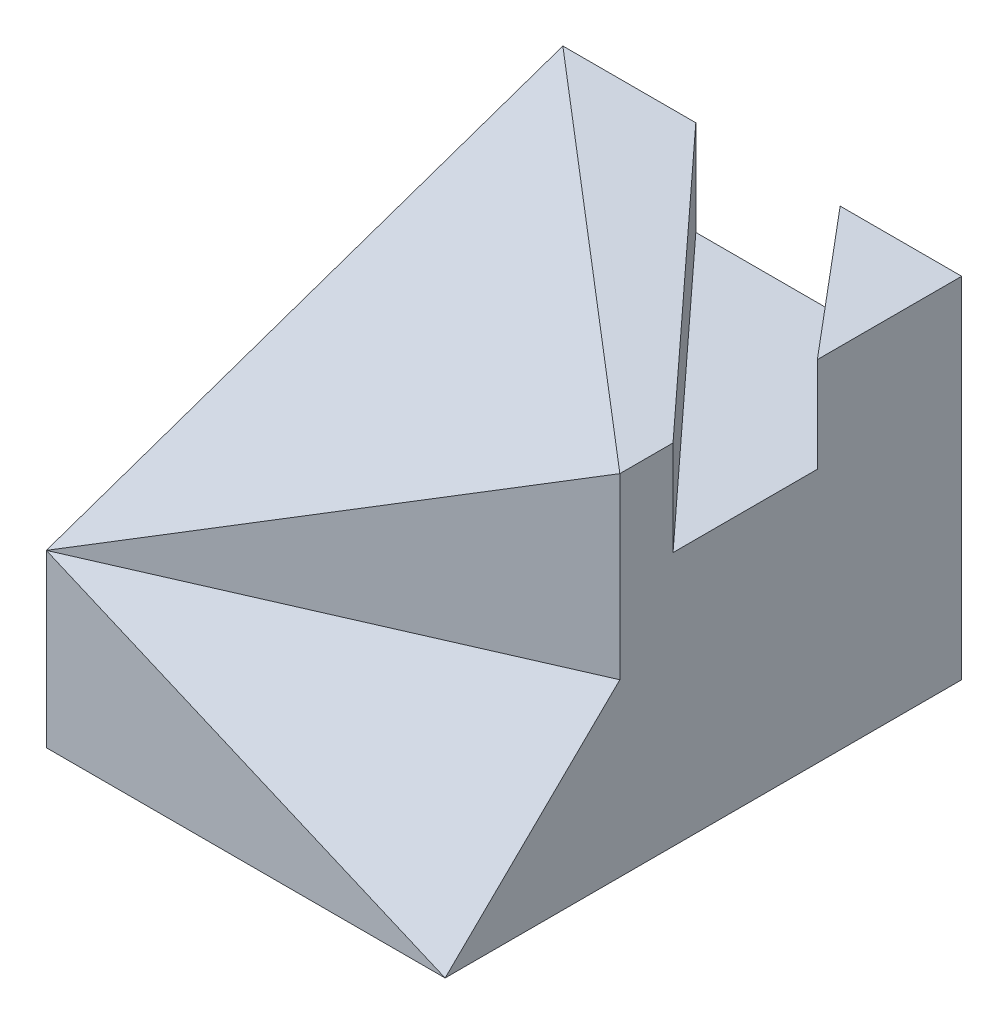
from build123d import *

# Parameters (mm, degrees)
SKETCH1_W           = 52.5
SKETCH1_H           = 68
BOSS_EXTRUDE1_DEPTH = 46
CUT_EXTRUDE1_DEPTH  = 12.5
CUT_EXTRUDE2_DEPTH  = 23.5
CUT_EXTRUDE3_REACH  = 71.46
CUT_EXTRUDE4_REACH  = 70.32


with BuildPart() as part:
    # Sketch1 → Boss-Extrude1 (new body)
    with BuildSketch(Plane(origin=(0, 0, 0), x_dir=(1, 0, 0), z_dir=(0, 1, 0))):
        Rectangle(SKETCH1_W, SKETCH1_H)
    extrude(amount=BOSS_EXTRUDE1_DEPTH)

    # Sketch2 → Cut-Extrude1 (cut)
    with BuildSketch(Plane(origin=(0, 46, 0), x_dir=(1, 0, 0), z_dir=(0, 1, 0))):
        Polygon((26.25, 15), (10.25, 34), (-8.75, 34), (26.25, -4), align=None)
    extrude(amount=-CUT_EXTRUDE1_DEPTH, mode=Mode.SUBTRACT)

    # Sketch2_3 → Cut-Extrude2 (cut)
    with BuildSketch(Plane(origin=(0, 46, 0), x_dir=(1, 0, 0), z_dir=(0, 1, 0))):
        Polygon((26.25, -34), (26.25, -11), (-26.25, -34), align=None)
    extrude(amount=-CUT_EXTRUDE2_DEPTH, mode=Mode.SUBTRACT)

    # Sketch3 → Cut-Extrude3 (cut, up to next)
    with BuildSketch(Plane(origin=(8.911278514, 20.792983199, 20.340961825), x_dir=(0.9561370461072578, -0.2093889663879971, -0.2048370323360841), z_dir=(0.29291969729140394, 0.6834792936799428, 0.6686210481651613)), mode=Mode.PRIVATE) as cut_extrude3_sk1:
        Polygon((18.134138361, 7.870944216), (-36.774308303, -8.570238372), (18.134138361, -24.30435687), align=None)
    cut_extrude3_tool1 = extrude(cut_extrude3_sk1.sketch, amount=CUT_EXTRUDE3_REACH, mode=Mode.PRIVATE) & part.part
    add(cut_extrude3_tool1.solids().sort_by_distance((8.75, 15, 26.333333))[0], mode=Mode.SUBTRACT)

    # Sketch4 → Cut-Extrude4 (cut, up to next)
    with BuildSketch(Plane(origin=(-10.312326736, 34.813244868, 12.031047859), x_dir=(-0.962971205375164, -0.2548167914482237, -0.08806168527990085), z_dir=(0.2696042611278684, -0.9101533921763496, -0.31453830464917976)), mode=Mode.PRIVATE) as cut_extrude4_sk1:
        Polygon((16.550519034, 47.160265119), (-37.968245086, 4.628461033), (16.550519034, -24.785895306), align=None)
    cut_extrude4_tool1 = extrude(cut_extrude4_sk1.sketch, amount=-CUT_EXTRUDE4_REACH, mode=Mode.PRIVATE) & part.part
    add(cut_extrude4_tool1.solids().sort_by_distance((-8.75, 38.166667, 3.666667))[0], mode=Mode.SUBTRACT)


solid = part.part
